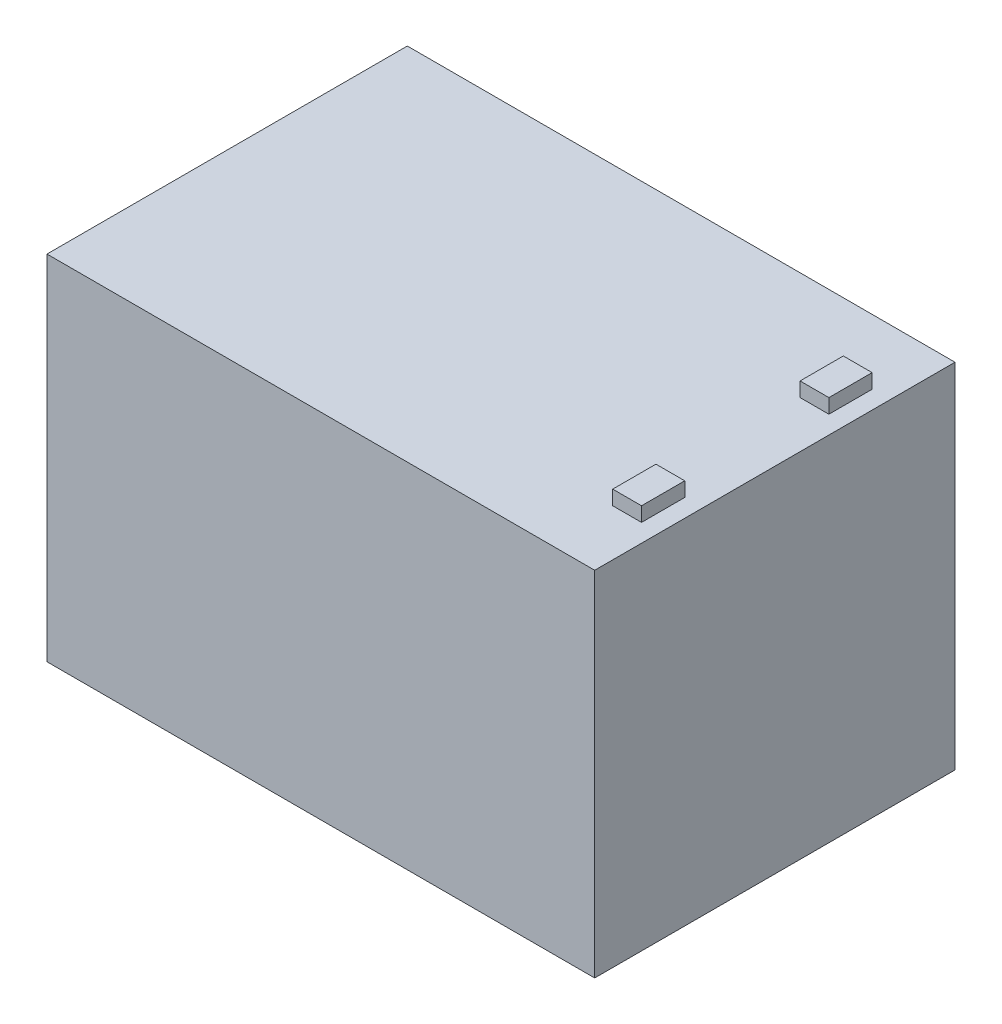
from build123d import *

# Parameters (mm, degrees)
SKETCH1_W           = 152
SKETCH1_H           = 98
BOSS_EXTRUDE1_DEPTH = 100
SKETCH2_W           = 8
SKETCH2_H           = 12
BOSS_EXTRUDE2_DEPTH = 4


with BuildPart() as part:
    # Sketch1 → Boss-Extrude1 (new body)
    with BuildSketch(Plane.XY):
        Rectangle(SKETCH1_W, SKETCH1_H)
    extrude(amount=BOSS_EXTRUDE1_DEPTH)

    # Sketch2 → Boss-Extrude2 (add)
    with BuildSketch(Plane(origin=(0, 49, 0), x_dir=(1, 0, 0), z_dir=(0, 1, 0))):
        with Locations((67, -24)):
            Rectangle(SKETCH2_W, SKETCH2_H)
        with Locations((67, -76)):
            Rectangle(SKETCH2_W, SKETCH2_H)
    extrude(amount=BOSS_EXTRUDE2_DEPTH)


solid = part.part
